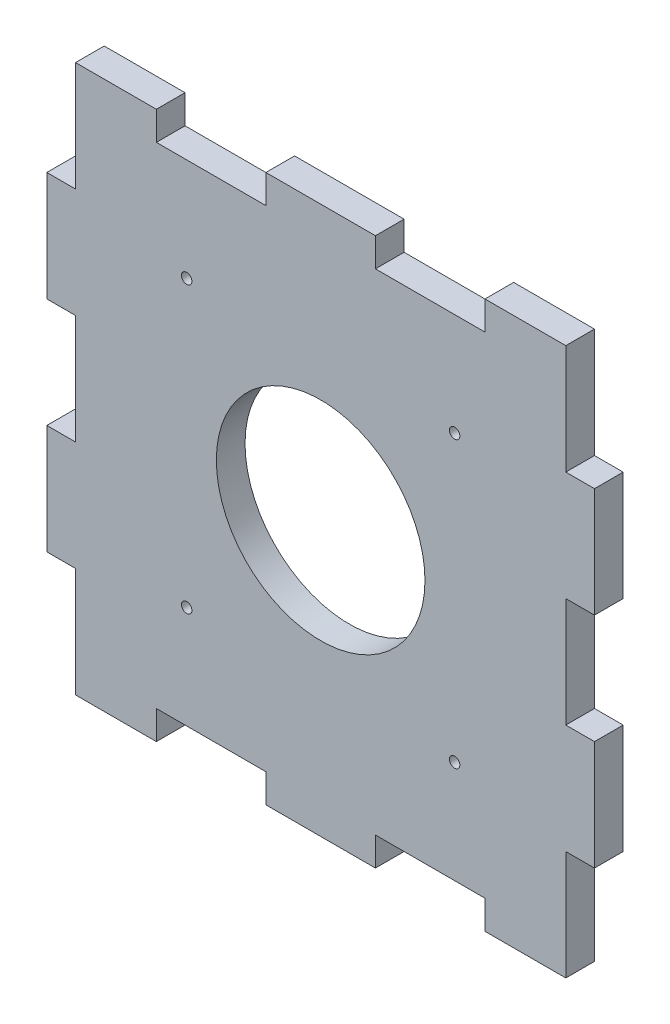
from build123d import *

# Parameters (mm, degrees)
CROQUIS1_R              = 20
CROQUIS1_R_2            = 1
SALIENTE_EXTRUIR1_DEPTH = 5.5
CROQUIS2_W              = 5.5
CROQUIS2_H              = 21
SALIENTE_EXTRUIR2_DEPTH = 2.5
CROQUIS3_W              = 15.5
CROQUIS3_H              = 5.5
CROQUIS3_W_2            = 21
SALIENTE_EXTRUIR3_DEPTH = 2.5
CROQUIS4_W              = 5.5
CROQUIS4_H              = 21
SALIENTE_EXTRUIR4_DEPTH = 2.5
CROQUIS5_W              = 15.5
CROQUIS5_H              = 5.5
CROQUIS5_W_2            = 21
SALIENTE_EXTRUIR5_DEPTH = 2.5


with BuildPart() as part:
    # Croquis1 → Saliente-Extruir1 (new body)
    with BuildSketch(Plane.XY):
        Polygon((-47, 50), (-47, 31.5), (-50, 31.5), (-50, 10.5), (-47, 10.5), (-47, -10.5), (-50, -10.5), (-50, -31.5), (-47, -31.5), (-47, -50), (-31.5, -50), (-31.5, -47), (-10.5, -47), (-10.5, -50), (10.5, -50), (10.5, -47), (31.5, -47), (31.5, -50), (47, -50), (47, -31.5), (50, -31.5), (50, -10.5), (47, -10.5), (47, 10.5), (50, 10.5), (50, 31.5), (47, 31.5), (47, 50), (31.5, 50), (31.5, 47), (10.5, 47), (10.5, 50), (-10.5, 50), (-10.5, 47), (-31.5, 47), (-31.5, 50), align=None)
        Circle(CROQUIS1_R, mode=Mode.SUBTRACT)
        with Locations((25.684125329, 27.323537584)):
            Circle(CROQUIS1_R_2, mode=Mode.SUBTRACT)
        with Locations((25.684125329, -27.323537584)):
            Circle(CROQUIS1_R_2, mode=Mode.SUBTRACT)
        with Locations((-25.684125329, 27.323537584)):
            Circle(CROQUIS1_R_2, mode=Mode.SUBTRACT)
        with Locations((-25.684125329, -27.323537584)):
            Circle(CROQUIS1_R_2, mode=Mode.SUBTRACT)
    extrude(amount=SALIENTE_EXTRUIR1_DEPTH)

    # Croquis2 → Saliente-Extruir2 (add)
    with BuildSketch(Plane(origin=(50, 0, 0), x_dir=(0, 0, -1), z_dir=(1, 0, 0))):
        with Locations((-2.75, -21)):
            Rectangle(CROQUIS2_W, CROQUIS2_H)
        with Locations((-2.75, 21)):
            Rectangle(CROQUIS2_W, CROQUIS2_H)
    extrude(amount=SALIENTE_EXTRUIR2_DEPTH)

    # Croquis3 → Saliente-Extruir3 (add)
    with BuildSketch(Plane.XZ.offset(50)):
        with Locations((39.25, 2.75)):
            Rectangle(CROQUIS3_W, CROQUIS3_H)
        with Locations((0, 2.75)):
            Rectangle(CROQUIS3_W_2, CROQUIS3_H)
        with Locations((-39.25, 2.75)):
            Rectangle(CROQUIS3_W, CROQUIS3_H)
    extrude(amount=SALIENTE_EXTRUIR3_DEPTH)

    # Croquis4 → Saliente-Extruir4 (add)
    with BuildSketch(Plane.ZY.offset(50)):
        with Locations((2.75, -21)):
            Rectangle(CROQUIS4_W, CROQUIS4_H)
        with Locations((2.75, 21)):
            Rectangle(CROQUIS4_W, CROQUIS4_H)
    extrude(amount=SALIENTE_EXTRUIR4_DEPTH)

    # Croquis5 → Saliente-Extruir5 (add)
    with BuildSketch(Plane(origin=(0, 50, 0), x_dir=(1, 0, 0), z_dir=(0, 1, 0))):
        with Locations((-39.25, -2.75)):
            Rectangle(CROQUIS5_W, CROQUIS5_H)
        with Locations((0, -2.75)):
            Rectangle(CROQUIS5_W_2, CROQUIS5_H)
        with Locations((39.25, -2.75)):
            Rectangle(CROQUIS5_W, CROQUIS5_H)
    extrude(amount=SALIENTE_EXTRUIR5_DEPTH)


solid = part.part
